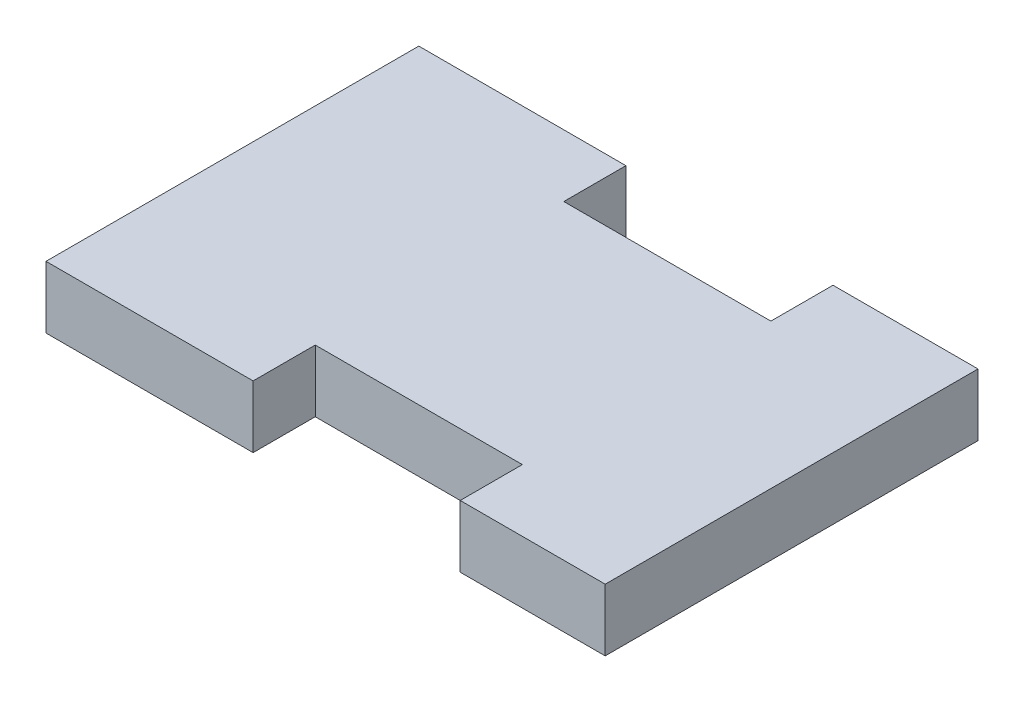
from build123d import *

# Parameters (mm, degrees)
AUFSATZ_LINEAR_AUSTRAGEN1_DEPTH = 3


with BuildPart() as part:
    # Skizze1 → Aufsatz-Linear austragen1 (new body)
    with BuildSketch(Plane(origin=(0, 0, 0), x_dir=(1, 0, 0), z_dir=(0, 1, 0))):
        Polygon((0, 0), (10.000234, 0), (10.000234, 2.999994), (19.999198, 2.999994), (19.999198, 0), (26.999692, 0), (26.999692, 17.999964), (19.999198, 17.999964), (19.999198, 14.99997), (10.000234, 14.99997), (10.000234, 17.999964), (0, 17.999964), align=None)
    extrude(amount=AUFSATZ_LINEAR_AUSTRAGEN1_DEPTH)


solid = part.part
